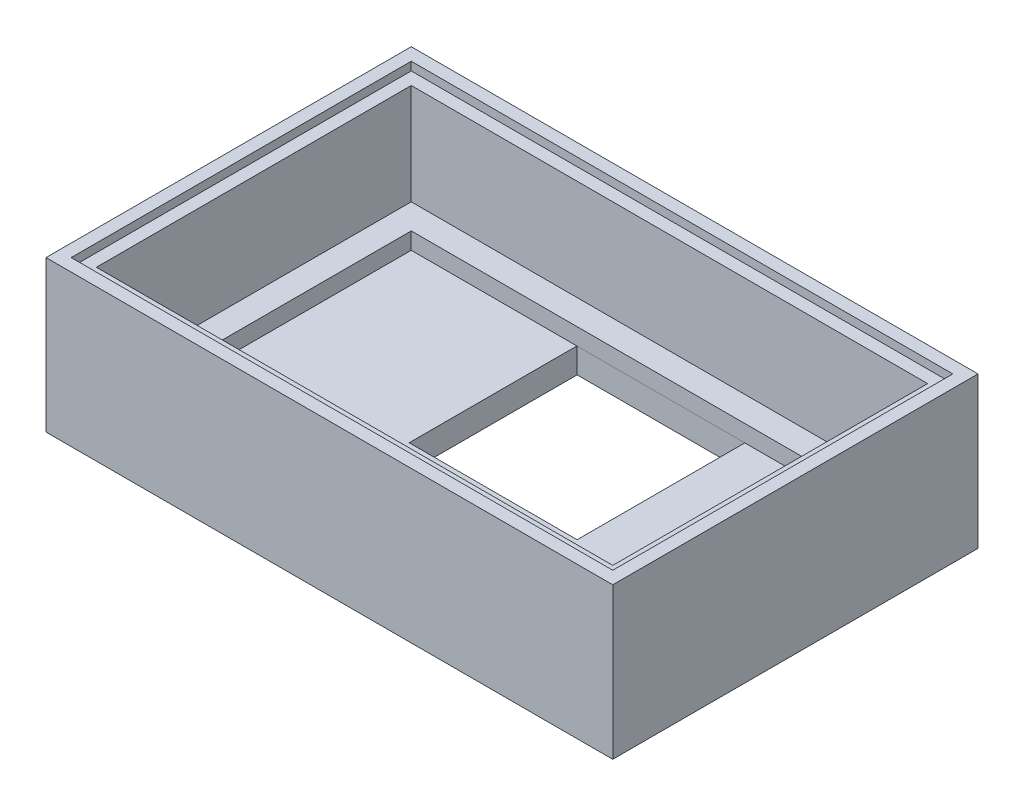
from build123d import *

# Parameters (mm, degrees)
SKETCH_1_W          = 61.5
SKETCH_1_H          = 37.5
SKETCH_1_W_2        = 55.5
SKETCH_1_H_2        = 33
EXTRUDE_2_DEPTH     = 2
SKETCH_1_4_W        = 67.5
SKETCH_1_4_H        = 43.5
SKETCH_1_4_W_2      = 61.5
SKETCH_1_4_H_2      = 37.5
EXTRUDE_3_DEPTH     = 15
SKETCH_1_5_W        = 67.5
SKETCH_1_5_H        = 43.5
EXTRUDE_4_DEPTH     = 3
CUT_EXTRUDE_1_REACH = 77.757
SKETCH_1_6_W        = 4.5
SKETCH_1_6_H        = 4.5
SKETCH_3_W          = 64.5
SKETCH_3_H          = 40.5
CUT_EXTRUDE_2_DEPTH = 1
SKETCH_4_W          = 20
SKETCH_4_H          = 20
CUT_EXTRUDE_4_DEPTH = 76.757255238


with BuildPart() as part:
    # Эскиз1 → Бобышка-Вытянуть2 (new body)
    with BuildSketch(Plane(origin=(0, 0, 0), x_dir=(1, 0, 0), z_dir=(0, 1, 0))):
        with Locations((-28.437260101, -18.832094604)):
            Rectangle(SKETCH_1_W, SKETCH_1_H)
        with Locations((-28.437260101, -19.582094604)):
            Rectangle(SKETCH_1_W_2, SKETCH_1_H_2, mode=Mode.SUBTRACT)
    extrude(amount=EXTRUDE_2_DEPTH)

    # Эскиз1<4> → Бобышка-Вытянуть3 (add)
    with BuildSketch(Plane(origin=(0, 0, 0), x_dir=(1, 0, 0), z_dir=(0, 1, 0))):
        with Locations((-28.437260101, -18.832094604)):
            Rectangle(SKETCH_1_4_W, SKETCH_1_4_H)
        with Locations((-28.437260101, -18.832094604)):
            Rectangle(SKETCH_1_4_W_2, SKETCH_1_4_H_2, mode=Mode.SUBTRACT)
    extrude(amount=EXTRUDE_3_DEPTH)

    # Эскиз1<5> → Бобышка-Вытянуть4 (add)
    with BuildSketch(Plane(origin=(0, 0, 0), x_dir=(1, 0, 0), z_dir=(0, 1, 0))):
        with Locations((-28.437260101, -18.832094604)):
            Rectangle(SKETCH_1_5_W, SKETCH_1_5_H)
    extrude(amount=-EXTRUDE_4_DEPTH)

    # Эскиз1<6> → Вырез-Вытянуть1 (cut, up to next)
    with BuildSketch(Plane(origin=(0, 0, 0), x_dir=(1, 0, 0), z_dir=(0, 1, 0)), mode=Mode.PRIVATE) as cut_extrude_1_sk1:
        with Locations((-7.437260101, -32.782094604)):
            Rectangle(SKETCH_1_6_W, SKETCH_1_6_H)
    cut_extrude_1_tool1 = extrude(cut_extrude_1_sk1.sketch, amount=-CUT_EXTRUDE_1_REACH, mode=Mode.PRIVATE) & part.part
    add(cut_extrude_1_tool1.solids().sort_by_distance((-7.43726, 0, 32.782095))[0], mode=Mode.SUBTRACT)

    # Эскиз3 → Вырез-Вытянуть2 (cut)
    with BuildSketch(Plane(origin=(0, 15, 0), x_dir=(1, 0, 0), z_dir=(0, 1, 0))):
        with Locations((-28.437260101, -18.832094604)):
            Rectangle(SKETCH_3_W, SKETCH_3_H)
    extrude(amount=-CUT_EXTRUDE_2_DEPTH, mode=Mode.SUBTRACT)

    # Эскиз4 → Вырез-Вытянуть4 (cut, through all)
    with BuildSketch(Plane(origin=(0, 0, 0), x_dir=(1, 0, 0), z_dir=(0, 1, 0))):
        with Locations((-26.4581734, -13.054729736)):
            Rectangle(SKETCH_4_W, SKETCH_4_H)
    extrude(amount=-CUT_EXTRUDE_4_DEPTH, mode=Mode.SUBTRACT)


solid = part.part
